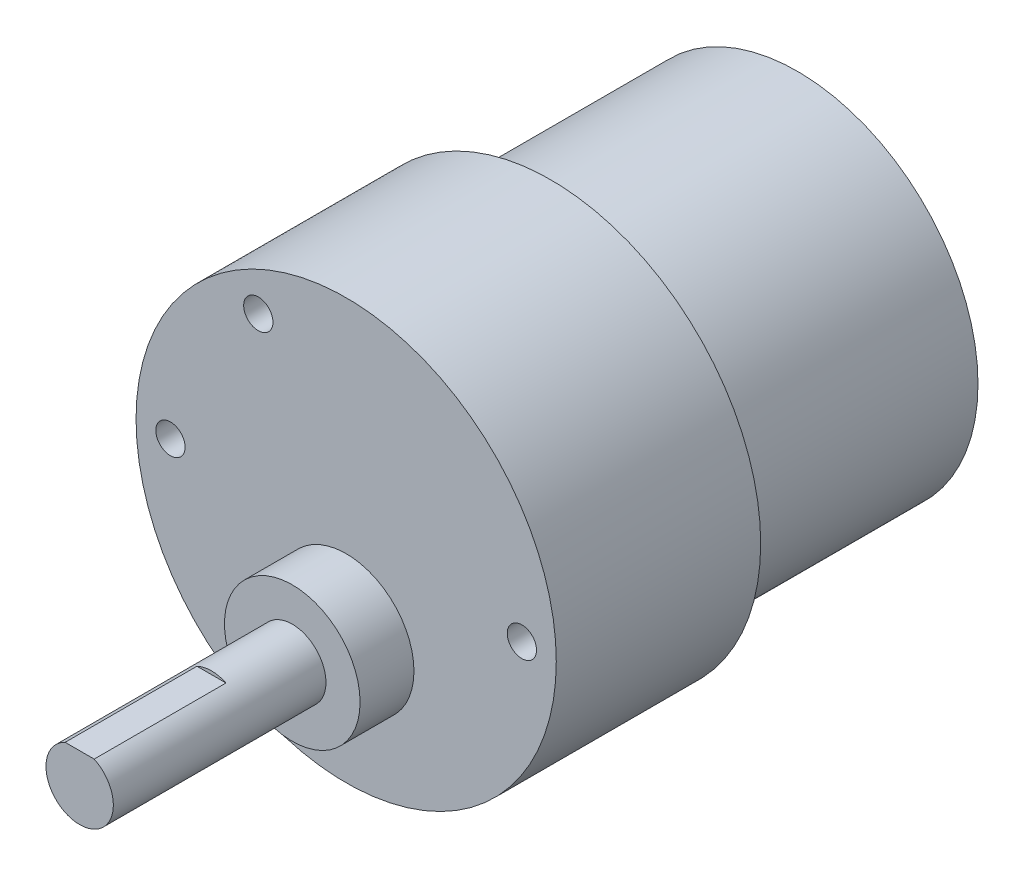
from build123d import *

# Parameters (mm, degrees)
SKETCH1_R          = 15.6591
MOTOR_DEPTH        = 21.4122
SKETCH3_R          = 18.2245
GEARBOX_DEPTH      = 17.7292
SKETCH4_R          = 5.8801
PROTRUSION_DEPTH   = 4.6736
SKETCH5_R          = 2.921
SHAFT_DEPTH        = 18.4404
SKETCH6_R          = 1.27
SCREW_HOLES_DEPTH  = 9.3472
SKETCH7_R          = 4.4577
NUB_DEPTH          = 2.921
CUT_EXTRUDE1_DEPTH = 11.43


with BuildPart() as part:
    # Sketch1 → motor (new body)
    with BuildSketch(Plane.XY):
        Circle(SKETCH1_R)
    extrude(amount=MOTOR_DEPTH)

    # Sketch3 → gearbox (add)
    with BuildSketch(Plane.XY.offset(21.4122)):
        Circle(SKETCH3_R)
    extrude(amount=GEARBOX_DEPTH)

    # Sketch4 → protrusion (add)
    with BuildSketch(Plane.XY.offset(39.1414)):
        with Locations((0, -6.8834)):
            Circle(SKETCH4_R)
    extrude(amount=PROTRUSION_DEPTH)

    # Sketch5 → shaft (add)
    with BuildSketch(Plane.XY.offset(43.815)):
        with Locations((0, -6.8834)):
            Circle(SKETCH5_R)
    extrude(amount=SHAFT_DEPTH)

    # Sketch6 → screw holes (cut)
    with BuildSketch(Plane.XY.offset(39.1414)):
        with Locations((15.24, 0)):
            Circle(SKETCH6_R)
        with Locations((-15.24, 0)):
            Circle(SKETCH6_R)
        with Locations((-7.62, -13.198227096)):
            Circle(SKETCH6_R)
        with Locations((-7.61999995, 13.198227183)):
            Circle(SKETCH6_R)
    extrude(amount=-SCREW_HOLES_DEPTH, mode=Mode.SUBTRACT)

    # Sketch7 → nub (add)
    with BuildSketch(Plane(origin=(0, 0, 0), x_dir=(-1, 0, 0), z_dir=(0, 0, -1))):
        with Locations(Location((0, 0, 0), (0, 0, 180))):  # turned: the seam where the file's is
            Circle(SKETCH7_R)
    extrude(amount=NUB_DEPTH)

    # Sketch8 → Cut-Extrude1 (cut)
    with BuildSketch(Plane.XY.offset(62.2554)):
        with BuildLine():
            Line((1.260039062, -4.24815), (-1.260039062, -4.24815))
            ThreePointArc((-1.260039062, -4.24815), (0, -3.9624), (1.260039062, -4.24815))
        make_face()
    extrude(amount=-CUT_EXTRUDE1_DEPTH, mode=Mode.SUBTRACT)


solid = part.part
